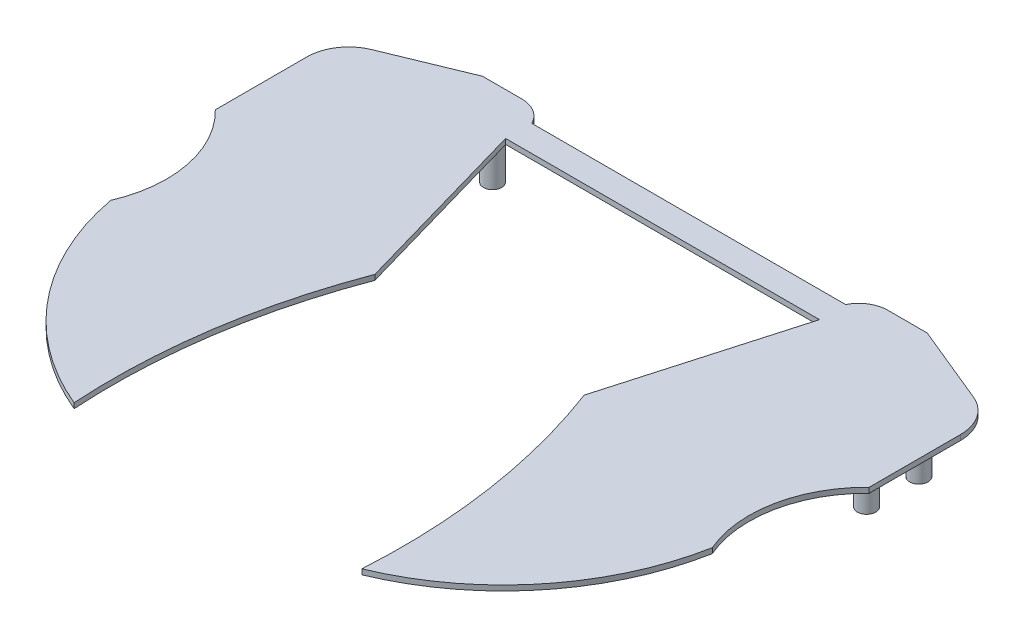
from build123d import *

# Parameters (mm, degrees)
SKETCH1_W           = 152.4
SKETCH1_H           = 12.7
BOSS_EXTRUDE1_DEPTH = 2.54
BOSS_EXTRUDE2_DEPTH = 2.54
SKETCH3_R           = 4.445
BOSS_EXTRUDE3_DEPTH = 25.4


with BuildPart() as part:
    # Sketch1 → Boss-Extrude1 (new body)
    with BuildSketch(Plane(origin=(0, 0, 0), x_dir=(1, 0, 0), z_dir=(0, 1, 0))):
        Rectangle(SKETCH1_W, SKETCH1_H)
    extrude(amount=BOSS_EXTRUDE1_DEPTH)

    # Sketch2 → Boss-Extrude2 (add)
    with BuildSketch(Plane(origin=(0, 0, 0), x_dir=(1, 0, 0), z_dir=(0, 1, 0))):
        with BuildLine():
            Line((88.9, 14.199031657), (107.95, 14.199031657))
            Line((107.95, 14.199031657), (146.163989052, -1.529369001))
            ThreePointArc((146.163989052, -1.529369001), (155.312787944, -9.011867032), (158.75, -20.32))
            Line((158.75, -20.32), (158.75, -64.77))
            ThreePointArc((158.75, -64.77), (142.538163249, -94.54763265), (146.05, -128.27))
            ThreePointArc((146.05, -128.27), (119.860653201, -184.91728638), (69.85, -222.25))
            ThreePointArc((69.85, -222.25), (67.089486, -157.7353271), (50.8, -95.25))
            Line((50.8, -95.25), (76.2, -6.35))
            Line((76.2, -6.35), (76.2, 6.35))
            ThreePointArc((76.2, 6.35), (81.435127296, 12.078417757), (88.9, 14.199031657))
        make_face()
    boss_extrude2 = extrude(amount=BOSS_EXTRUDE2_DEPTH)

    # Mirror1: Boss-Extrude2 across plane
    add(boss_extrude2.mirror(Plane(origin=(0, 0, 0), x_dir=(0, 0, 1), z_dir=(1, 0, 0))))

    # Sketch3 → Boss-Extrude3 (add)
    with BuildSketch(Plane.XZ):
        with Locations((88.9, 0)):
            Circle(SKETCH3_R)
        with Locations((138.43, 20.32)):
            Circle(SKETCH3_R)
        with Locations((138.43, 45.72)):
            Circle(SKETCH3_R)
        with Locations((-138.43, 45.72)):
            Circle(SKETCH3_R)
        with Locations((-138.43, 20.32)):
            Circle(SKETCH3_R)
        with Locations((-88.9, 0)):
            Circle(SKETCH3_R)
    extrude(amount=BOSS_EXTRUDE3_DEPTH)


solid = part.part
